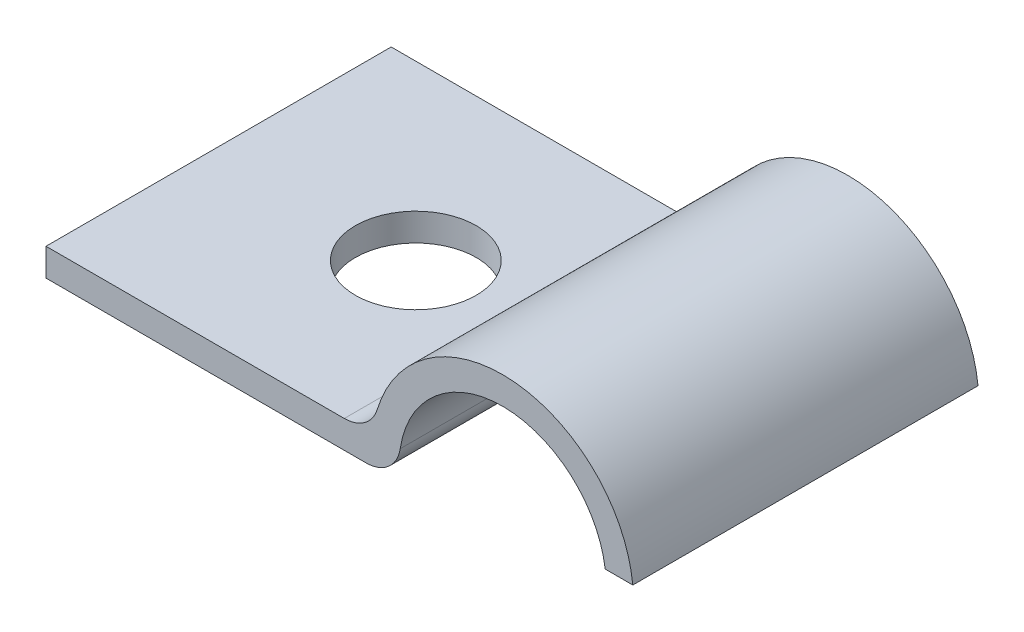
from build123d import *

# Parameters (mm, degrees)
BOSS_EXTRUDE1_DEPTH = 10
FILLET1_R           = 1
SKETCH3_R           = 1.75
CUT_EXTRUDE1_DEPTH  = 1.8


with BuildPart() as part:
    # Sketch2 → Boss-Extrude1 (new body)
    with BuildSketch(Plane.XY):
        with BuildLine():
            Line((0, 0), (10.253572501, 0))
            ThreePointArc((10.253572501, 0), (12.826786251, 3.373213749), (16.2, 0.8))
            Line((16.2, 0.8), (17, 0.8))
            ThreePointArc((17, 0.8), (13.226786251, 4.194356599), (9.453572501, 0.8))
            Line((9.453572501, 0.8), (0, 0.8))
            Line((0, 0.8), (0, 0))
        make_face()
    extrude(amount=BOSS_EXTRUDE1_DEPTH)

    # Fillet1
    fillet1_edges = [part.edges().sort_by_distance(p)[0] for p in [
        (9.453572501, 0.8, 5),
        (10.253572501, 0, 5),
    ]]
    fillet(fillet1_edges, radius=FILLET1_R)

    # Sketch3 → Cut-Extrude1 (cut, through all)
    with BuildSketch(Plane(origin=(0, 0.8, 0), x_dir=(1, 0, 0), z_dir=(0, 1, 0))):
        with Locations((5.713393125, -5)):
            Circle(SKETCH3_R)
    extrude(amount=-CUT_EXTRUDE1_DEPTH, mode=Mode.SUBTRACT)


solid = part.part
